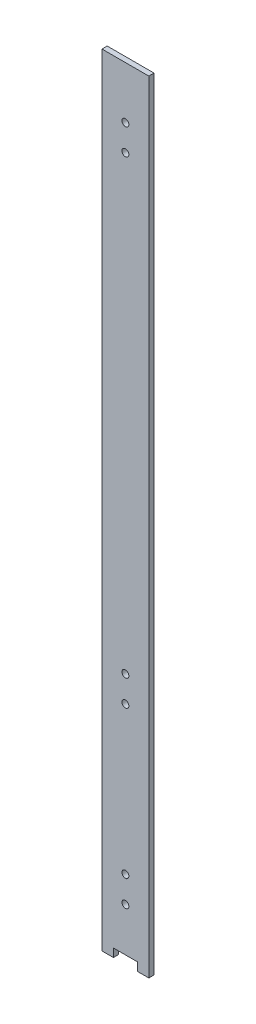
from build123d import *

# Parameters (mm, degrees)
SKETCH_1_W          = 27
SKETCH_1_H          = 3
EXTRUDE_1_DEPTH     = 450
SKETCH_2_W          = 13.830635844
SKETCH_2_H          = 9.55824336
CUT_EXTRUDE_1_DEPTH = 4
SKETCH_3_R          = 2
CUT_EXTRUDE_2_DEPTH = 4


with BuildPart() as part:
    # 草图1 → 凸台-拉伸1 (new body)
    with BuildSketch(Plane(origin=(0, 0, 0), x_dir=(1, 0, 0), z_dir=(0, 1, 0))):
        Rectangle(SKETCH_1_W, SKETCH_1_H)
    extrude(amount=EXTRUDE_1_DEPTH)

    # 草图2 → 切除-拉伸1 (cut, through all)
    with BuildSketch(Plane(origin=(0, 0, -1.5), x_dir=(-1, 0, 0), z_dir=(0, 0, -1))):
        Rectangle(SKETCH_2_W, SKETCH_2_H)
    extrude(amount=-CUT_EXTRUDE_1_DEPTH, mode=Mode.SUBTRACT)

    # 草图3 → 切除-拉伸2 (cut, through all)
    with BuildSketch(Plane(origin=(0, 0, -1.5), x_dir=(-1, 0, 0), z_dir=(0, 0, -1))):
        with Locations((0, 420)):
            Circle(SKETCH_3_R)
        with Locations((0, 405)):
            Circle(SKETCH_3_R)
        with Locations((0, 30)):
            Circle(SKETCH_3_R)
        with Locations((0, 45)):
            Circle(SKETCH_3_R)
        with Locations((0, 130)):
            Circle(SKETCH_3_R)
        with Locations((0, 145)):
            Circle(SKETCH_3_R)
    extrude(amount=-CUT_EXTRUDE_2_DEPTH, mode=Mode.SUBTRACT)


solid = part.part
